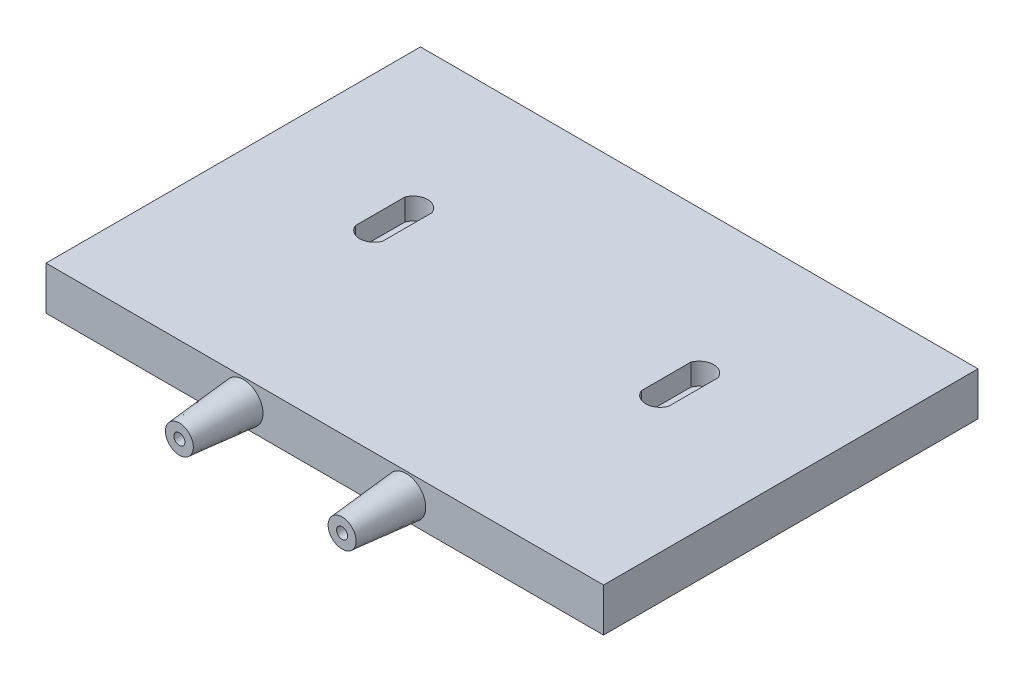
from build123d import *

# Parameters (mm, degrees)
SKETCH_1_W          = 156.75
SKETCH_1_H          = 105.271994628
EXTRUDE_1_DEPTH     = 12.2
SKETCH_2_W          = 7.639581741
SKETCH_2_H          = 13.89014237
CUT_EXTRUDE_1_DEPTH = 6.1
SKETCH_4_R          = 5.5
EXTRUDE_2_DEPTH     = 18
EXTRUDE_2_TAPER     = 5
CUT_EXTRUDE_2_REACH = 20
SKETCH_6_R          = 1.55
SKETCH_7_W          = 7
SKETCH_7_H          = 3.5
CUT_EXTRUDE_3_DEPTH = 9.1


with BuildPart() as part:
    # ｽｹｯﾁ1 → ﾎﾞｽ - 押し出し1 (new body)
    with BuildSketch(Plane(origin=(0, 0, 0), x_dir=(1, 0, 0), z_dir=(0, 1, 0))):
        Rectangle(SKETCH_1_W, SKETCH_1_H)
    extrude(amount=EXTRUDE_1_DEPTH)

    # ｽｹｯﾁ2 → ｶｯﾄ - 押し出し1 (cut)
    with BuildSketch(Plane(origin=(0, 12.2, 0), x_dir=(1, 0, 0), z_dir=(0, 1, 0))):
        with BuildLine():
            ThreePointArc((-44.016, 13.890145056), (-40.196209129, 16.500447871), (-36.376418259, 13.890145056))
            Line((-36.376418259, 13.890145056), (-44.016, 13.890145056))
        make_face()
        with Locations((-40.19620913, 6.945073871)):
            Rectangle(SKETCH_2_W, SKETCH_2_H)
        with BuildLine():
            Line((-44.016, 2.686e-06), (-36.376418259, 2.686e-06))
            ThreePointArc((-36.376418259, 2.686e-06), (-40.196209129, -2.610300128), (-44.016, 2.686e-06))
        make_face()
        with BuildLine():
            Line((44.016, 13.890145056), (36.376418259, 13.890145056))
            ThreePointArc((36.376418259, 13.890145056), (40.196209129, 16.500447871), (44.016, 13.890145056))
        make_face()
        with Locations((40.19620913, 6.945073871)):
            Rectangle(SKETCH_2_W, SKETCH_2_H)
        with BuildLine():
            ThreePointArc((44.016, 2.686e-06), (40.196209129, -2.610300128), (36.376418259, 2.686e-06))
            Line((36.376418259, 2.686e-06), (44.016, 2.686e-06))
        make_face()
    extrude(amount=-CUT_EXTRUDE_1_DEPTH, mode=Mode.SUBTRACT)

    # ｽｹｯﾁ4 → ﾎﾞｽ - 押し出し2 (add)
    with BuildSketch(Plane.XY.offset(52.635997314)):
        with Locations((-22.875, 6.1)):
            Circle(SKETCH_4_R)
        with Locations((22.875, 6.1)):
            Circle(SKETCH_4_R)
    extrude(amount=EXTRUDE_2_DEPTH, taper=EXTRUDE_2_TAPER)

    # ｽｹｯﾁ6 → ｶｯﾄ - 押し出し2 (cut, up to next)
    with BuildSketch(Plane.XY.offset(52.635997314), mode=Mode.PRIVATE) as cut_extrude_2_sk1:
        with Locations((-22.875, 6.1)):
            Circle(SKETCH_6_R)
    cut_extrude_2_tool1 = extrude(cut_extrude_2_sk1.sketch, amount=CUT_EXTRUDE_2_REACH, mode=Mode.PRIVATE) & part.part
    add(cut_extrude_2_tool1.solids().sort_by_distance((-22.875, 6.1, 52.635997))[0], mode=Mode.SUBTRACT)
    # ｽｹｯﾁ6 → ｶｯﾄ - 押し出し2 (cut, up to next)
    with BuildSketch(Plane.XY.offset(52.635997314), mode=Mode.PRIVATE) as cut_extrude_2_sk2:
        with Locations((22.875, 6.1)):
            Circle(SKETCH_6_R)
    cut_extrude_2_tool2 = extrude(cut_extrude_2_sk2.sketch, amount=CUT_EXTRUDE_2_REACH, mode=Mode.PRIVATE) & part.part
    add(cut_extrude_2_tool2.solids().sort_by_distance((22.875, 6.1, 52.635997))[0], mode=Mode.SUBTRACT)

    # ｽｹｯﾁ7 → ｶｯﾄ - 押し出し3 (cut)
    with BuildSketch(Plane(origin=(0, 0, 0), x_dir=(1, 0, 0), z_dir=(0, 1, 0))):
        with Locations((-22.875, -58.885997314)):
            Rectangle(SKETCH_7_W, SKETCH_7_H)
        with Locations((22.875, -58.885997314)):
            Rectangle(SKETCH_7_W, SKETCH_7_H)
    extrude(amount=CUT_EXTRUDE_3_DEPTH, mode=Mode.SUBTRACT)


solid = part.part
